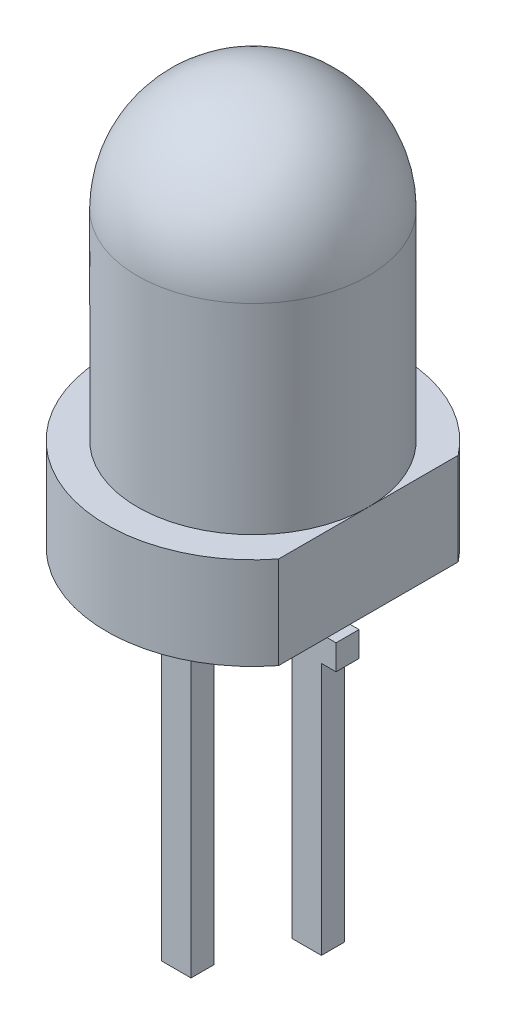
from build123d import *

# Parameters (mm, degrees)
CUT_EXTRUDE1_DEPTH    = 10
SKETCH3_W             = 0.383062026
SKETCH3_H             = 0.298484562
BOSS_EXTRUDE1_DEPTH   = 4
BOSS_EXTRUDE1_2_DEPTH = 4
BOSS_EXTRUDE2_DEPTH   = 0.15
SKETCH5_R             = 0.189425794
BOSS_EXTRUDE3_DEPTH   = 0.1
SKETCH6_W             = 0.76464177
SKETCH6_H             = 0.32650208
BOSS_EXTRUDE4_DEPTH   = 0.298485
SKETCH7_W             = 0.383062026
SKETCH7_H             = 0.298484562
BOSS_EXTRUDE5_DEPTH   = 1.1


with BuildPart() as part:
    # Sketch1 → Revolve1 (revolve)
    with BuildSketch(Plane.XY):
        with BuildLine():
            Line((0, 0), (-1.9, 0))
            Line((-1.9, 0), (-1.9, 1.2))
            Line((-1.9, 1.2), (-1.5, 1.2))
            Line((-1.5, 1.2), (-1.5, 3.8))
            ThreePointArc((-1.5, 3.8), (-1.060660172, 4.860660172), (0, 5.3))
            Line((0, 5.3), (0, 0))
        make_face()
    revolve(axis=Axis((0, 0, 0), (0, 1, 0)))

    # Sketch2 → Cut-Extrude1 (cut)
    with BuildSketch(Plane(origin=(0, 1.2, 0), x_dir=(1, 0, 0), z_dir=(0, 1, 0))):
        Polygon((1.5, 0), (1.5, 1.304892702), (2.01361065, 1.304892702), (2.01361065, -1.92540112), (1.5, -1.92540112), align=None)
    extrude(amount=-CUT_EXTRUDE1_DEPTH, mode=Mode.SUBTRACT)


with BuildPart() as body_2:
    # Sketch3 → Boss-Extrude1 (new body)
    with BuildSketch(Plane.XZ):
        with Locations((-0.846347528, 0)):
            Rectangle(SKETCH3_W, SKETCH3_H)
    extrude(amount=BOSS_EXTRUDE1_DEPTH)


with BuildPart() as body_3:
    # Sketch3 → Boss-Extrude1 2 (new body)
    with BuildSketch(Plane.XZ):
        with Locations((0.846347528, 0)):
            Rectangle(SKETCH3_W, SKETCH3_H)
    extrude(amount=BOSS_EXTRUDE1_2_DEPTH)


    add(body_2.part)  # Boss-Extrude2 merges body 2
    # Sketch4 → Boss-Extrude2 (add, symmetric)
    with BuildSketch(Plane.XY):
        Polygon((1.037878541, 2.260445566), (0.294117621, 2.788795467), (0.235969658, 2.706940276), (-0.385685641, 2.706940276), (-0.512741887, 2.796720697), (-0.565939225, 2.796720697), (-0.565939225, 2.617159855), (-0.565939225, 2.418450997), (0.654816515, 1.551255429), (0.654816515, 0), (1.037878541, 0), (1.037878541, 1.551255429), align=None)
        Polygon((0.482142428, 1.551255429), (-0.665939225, 2.366825071), (-0.665939225, 2.617159855), (-1.037878541, 2.617159855), (-1.037878541, 1.551255429), (-1.037878541, 0), (-0.654816515, 0), (-0.654816515, 1.551255429), align=None)
    extrude(amount=BOSS_EXTRUDE2_DEPTH, both=True)

    # Sketch6 → Boss-Extrude4 (add)
    with BuildSketch(Plane.XY.offset(0.149242281)):
        with Locations((0.846347528, -0.550865225)):
            Rectangle(SKETCH6_W, SKETCH6_H)
        with Locations((-0.846347528, -0.550865225)):
            Rectangle(SKETCH6_W, SKETCH6_H)
    extrude(amount=-BOSS_EXTRUDE4_DEPTH)

    # Sketch7 → Boss-Extrude5 (add)
    with BuildSketch(Plane.XZ.offset(4)):
        with Locations((-0.846347528, 0)):
            Rectangle(SKETCH7_W, SKETCH7_H)
    extrude(amount=BOSS_EXTRUDE5_DEPTH)


with BuildPart() as body_3_2:
    # Sketch5 → Boss-Extrude3 (new body)
    with BuildSketch(Plane(origin=(0, 2.706940276, 0), x_dir=(1, 0, 0), z_dir=(0, 1, 0))):
        with Locations((-0.060559566, 0)):
            Circle(SKETCH5_R)
    extrude(amount=BOSS_EXTRUDE3_DEPTH)


solid = Compound([part.part, body_3.part, body_3_2.part])
